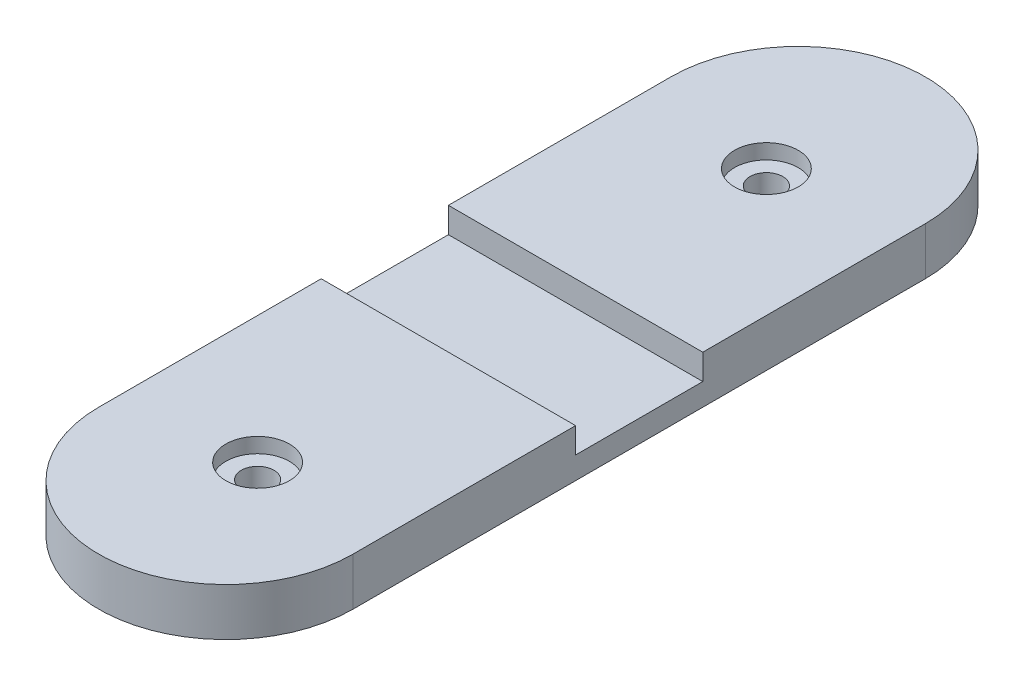
from build123d import *

# Parameters (mm, degrees)
BOSS_EXTRUDE1_DEPTH                            = 4.7625
CBORE_FOR_4_BUTTON_HEAD_CAP_SCREW1_D           = 3.2639
CBORE_FOR_4_BUTTON_HEAD_CAP_SCREW1_CBORE_D     = 6.35
CBORE_FOR_4_BUTTON_HEAD_CAP_SCREW1_CBORE_DEPTH = 1.4986
SKETCH6_W                                      = 25.4
SKETCH6_H                                      = 12.7
CUT_EXTRUDE1_DEPTH                             = 2.54


with BuildPart() as part:
    # Sketch1 → Boss-Extrude1 (new body)
    with BuildSketch(Plane(origin=(0, 0, 0), x_dir=(1, 0, 0), z_dir=(0, 1, 0))):
        with BuildLine():
            Line((-12.7, -28.575), (-12.7, 28.575))
            ThreePointArc((-12.7, 28.575), (0, 41.275), (12.7, 28.575))
            Line((12.7, 28.575), (12.7, -28.575))
            ThreePointArc((12.7, -28.575), (0, -41.275), (-12.7, -28.575))
        make_face()
    extrude(amount=BOSS_EXTRUDE1_DEPTH)

    # CBORE for #4 Button Head Cap Screw1 (through all)
    with Locations(Plane(origin=(0, 4.7625, 0), x_dir=(-1, 0, 0), z_dir=(0, 1, 0))):
        with Locations((0, 25.4), (0, -25.4)):
            CounterBoreHole(CBORE_FOR_4_BUTTON_HEAD_CAP_SCREW1_D / 2, CBORE_FOR_4_BUTTON_HEAD_CAP_SCREW1_CBORE_D / 2, CBORE_FOR_4_BUTTON_HEAD_CAP_SCREW1_CBORE_DEPTH)

    # Sketch6 → Cut-Extrude1 (cut)
    with BuildSketch(Plane(origin=(0, 4.7625, 0), x_dir=(1, 0, 0), z_dir=(0, 1, 0))):
        Rectangle(SKETCH6_W, SKETCH6_H)
    extrude(amount=-CUT_EXTRUDE1_DEPTH, mode=Mode.SUBTRACT)


solid = part.part
